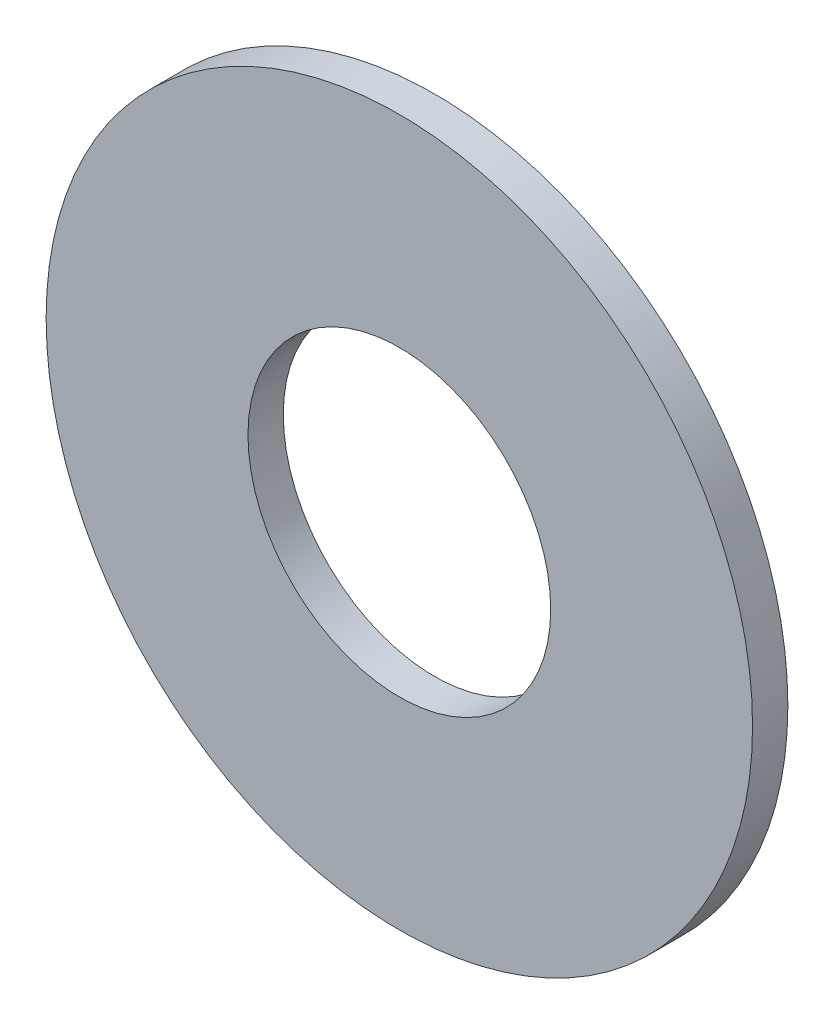
from build123d import *

# Parameters (mm, degrees)
ESQUISSE1_R             = 7
BOSS_EXTRU_1_DEPTH      = 0.7
ESQUISSE2_R             = 3
ENL_V_MAT_EXTRU_1_DEPTH = 1.5


with BuildPart() as part:
    # Esquisse1 → Boss.-Extru.1 (new body)
    with BuildSketch(Plane.XY):
        Circle(ESQUISSE1_R)
    extrude(amount=BOSS_EXTRU_1_DEPTH)

    # Esquisse2 → Enlèv. mat.-Extru.1 (cut)
    with BuildSketch(Plane.XY.offset(0.7)):
        Circle(ESQUISSE2_R)
    extrude(amount=-ENL_V_MAT_EXTRU_1_DEPTH, mode=Mode.SUBTRACT)


solid = part.part
